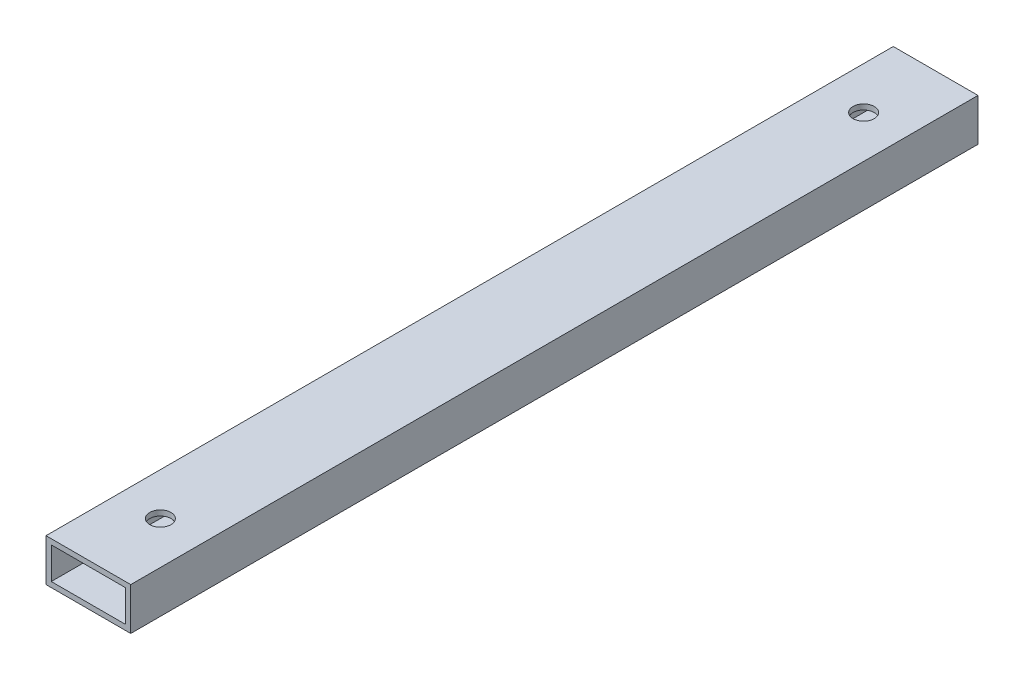
from build123d import *

# Parameters (mm, degrees)
SKETCH1_W           = 50.8
SKETCH1_H           = 25.4
SKETCH1_W_2         = 44.45
SKETCH1_H_2         = 19.05
EXTRUDE_THIN1_DEPTH = 508
SKETCH2_R           = 6.35
CUT_EXTRUDE1_DEPTH  = 26.4


with BuildPart() as part:
    # Sketch1 → Extrude-Thin1 (new body)
    with BuildSketch(Plane.XY):
        Rectangle(SKETCH1_W, SKETCH1_H)
        Rectangle(SKETCH1_W_2, SKETCH1_H_2, mode=Mode.SUBTRACT)
    extrude(amount=EXTRUDE_THIN1_DEPTH)

    # Sketch2 → Cut-Extrude1 (cut, through all)
    with BuildSketch(Plane(origin=(0, 12.7, 0), x_dir=(1, 0, 0), z_dir=(0, 1, 0))):
        with Locations((0, -464.82)):
            Circle(SKETCH2_R)
        with Locations((0, -43.18)):
            Circle(SKETCH2_R)
    extrude(amount=-CUT_EXTRUDE1_DEPTH, mode=Mode.SUBTRACT)


solid = part.part
